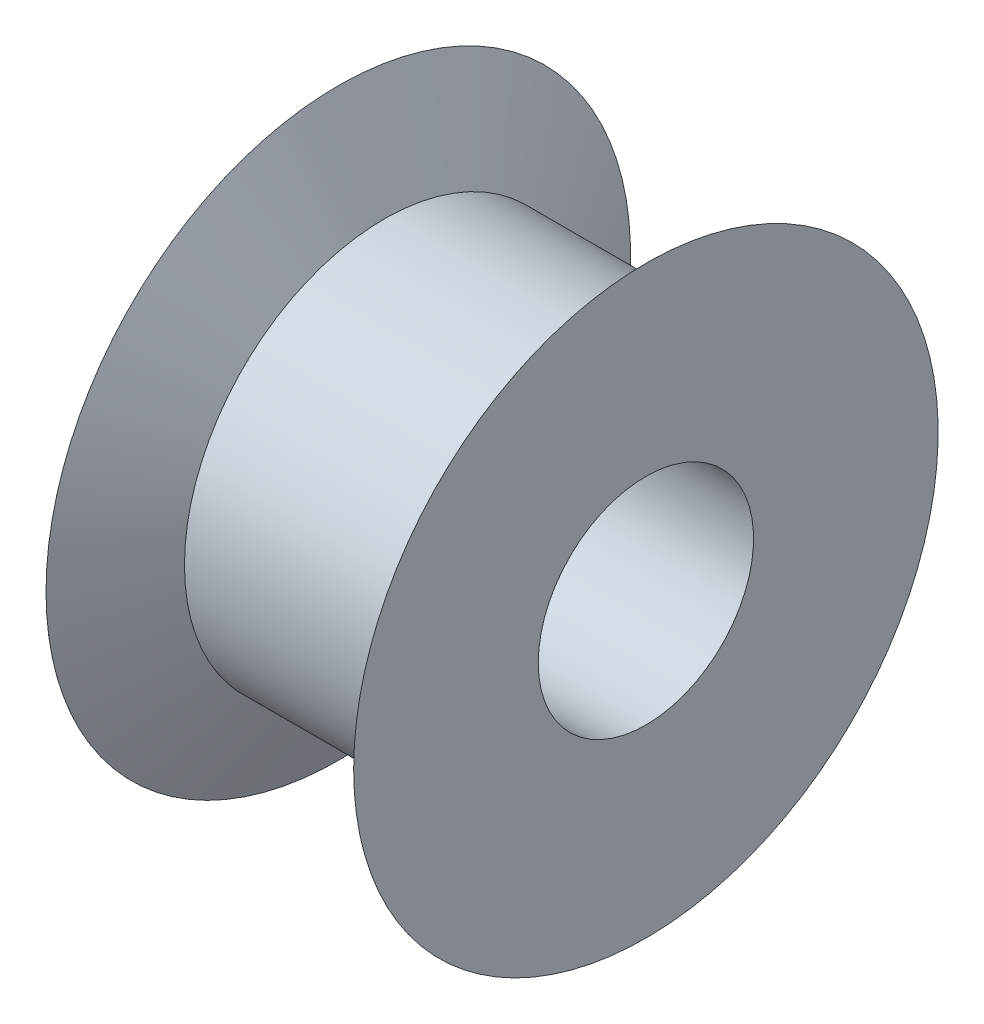
from build123d import *


with BuildPart() as part:
    # Sketch1 → Revolve1 (revolve)
    with BuildSketch(Plane(origin=(0, 0, 0), x_dir=(1, 0, 0), z_dir=(0, 1, 0))):
        Polygon((21.741158446, 3.5), (11.741158446, 3.5), (11.741158446, 9.5), (13.241158446, 6.5), (20.241158446, 6.5), (21.741158446, 9.5), align=None)
    revolve(axis=Axis((0, 0, 0), (1, 0, 0)))


solid = part.part
